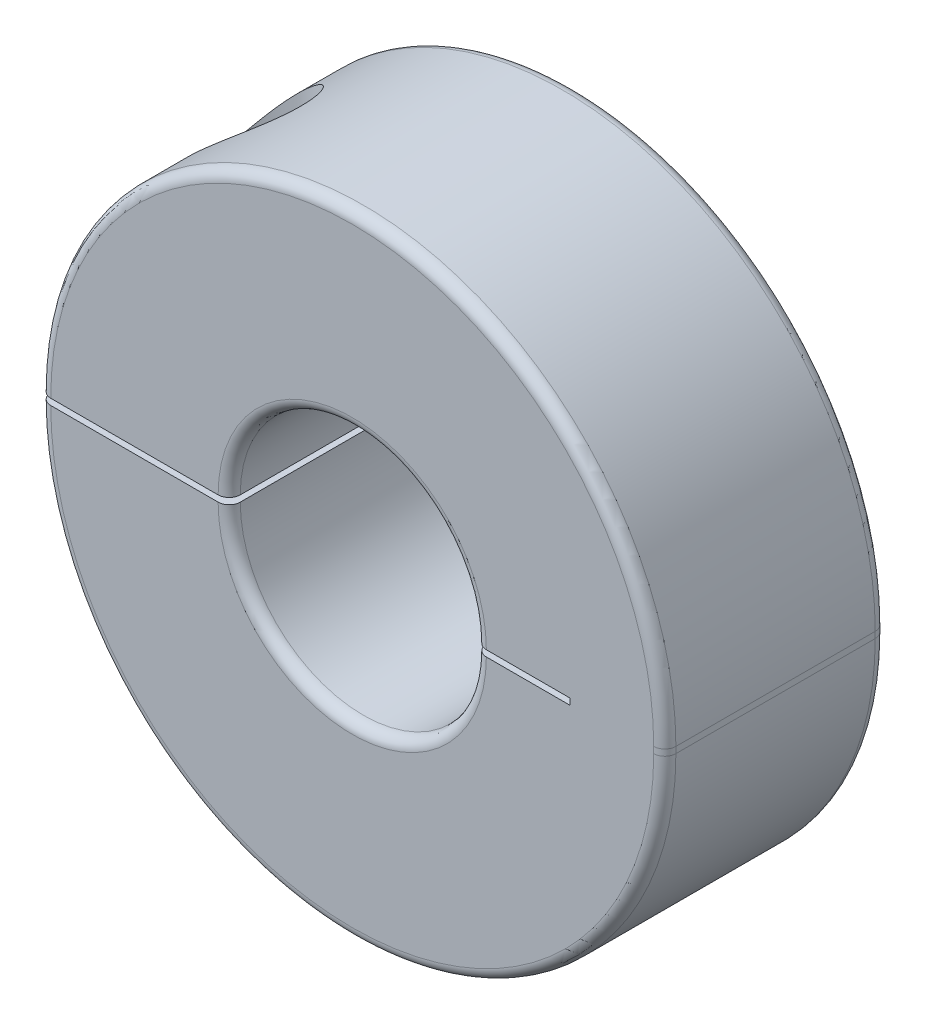
from build123d import *

# Parameters (mm, degrees)
EXTRUDE1_DEPTH     = 4.5
CUT_EXTRUDE2_DEPTH = 1.5
FILLET1_R          = 0.45
FILLET2_R          = 0.45
CHAMFER2_SIZE      = 0.254


with BuildPart() as part:
    # Sketch1 → Extrude1 (new body, symmetric)
    with BuildSketch(Plane.XY):
        with BuildLine():
            Line((-12.7, 0.127), (-5, 0.127))
            ThreePointArc((-5, 0.127), (0, 5.127), (5, 0.127))
            Line((5, 0.127), (8.85, 0.127))
            Line((8.85, 0.127), (8.85, -0.127))
            Line((8.85, -0.127), (5, -0.127))
            ThreePointArc((5, -0.127), (0, -5.127), (-5, -0.127))
            Line((-5, -0.127), (-12.7, -0.127))
            ThreePointArc((-12.7, -0.127), (0, -12.827), (12.7, -0.127))
            Line((12.7, -0.127), (12.7, 0.127))
            ThreePointArc((12.7, 0.127), (0, 12.827), (-12.7, 0.127))
        make_face()
    extrude(amount=EXTRUDE1_DEPTH, both=True)

    # Sketch4 → Cut-Revolve1 (revolve, cut)
    with BuildSketch(Plane.XY):
        Polygon((-8.85, 12.827), (-6.6, 12.827), (-6.6, 1.627), (-7.35, 1.627), (-7.35, -12.827), (-8.85, -12.827), align=None)
    revolve(axis=Axis((-8.85, -12.827, 0), (0, 1, 0)), mode=Mode.SUBTRACT)

    # Fillet1
    fillet1_edges = [part.edges().sort_by_distance(p)[0] for p in [
        (0, 5.127, 4.5),
        (0, 5.127, -4.5),
        (0, 12.827, -4.5),
        (0, -12.827, 4.5),
        (12.7, 0, 4.5),
        (0, 12.827, 4.5),
        (12.7, 0, -4.5),
        (0, -12.827, -4.5),
    ]]
    fillet(fillet1_edges, radius=FILLET1_R)

    # Fillet2
    fillet2_edges = [part.edges().sort_by_distance(p)[0] for p in [
        (0, -5.127, 4.5),
        (0, -5.127, -4.5),
    ]]
    fillet(fillet2_edges, radius=FILLET2_R)


with BuildPart() as body_2:
    # Sketch6 → Revolve1 (revolve)
    with BuildSketch(Plane.XY):
        Polygon((-8.85, 4.627), (-6.6, 4.627), (-6.6, 1.627), (-7.35, 1.627), (-7.35, -4.373), (-8.85, -4.373), align=None)
    revolve(axis=Axis((-8.85, -4.373, 0), (0, 1, 0)))

    # Sketch7 → Cut-Extrude2 (cut)
    with BuildSketch(Plane(origin=(0, 4.627, 0), x_dir=(-1, 0, 0), z_dir=(0, 1, 0))):
        Polygon((8.85, -1.385640646), (10.05, -0.692820323), (10.05, 0.692820323), (8.85, 1.385640646), (7.65, 0.692820323), (7.65, -0.692820323), align=None)
    extrude(amount=-CUT_EXTRUDE2_DEPTH, mode=Mode.SUBTRACT)

    # Chamfer2
    chamfer2_edges = [body_2.edges().sort_by_distance(p)[0] for p in [
        (-11.1, 4.627, 0),
    ]]
    chamfer(chamfer2_edges, length=CHAMFER2_SIZE)


solid = Compound([part.part, body_2.part])
